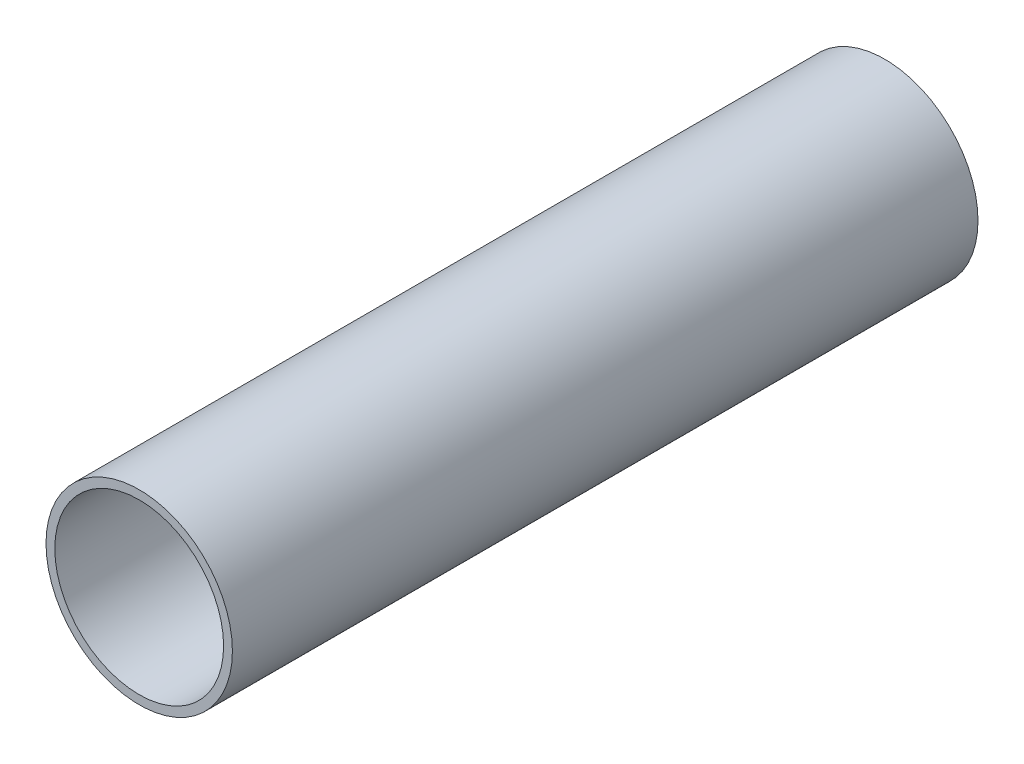
from build123d import *

# Parameters (mm, degrees)
SKETCH1_R           = 84.1375
SKETCH1_R_2         = 76.2
BOSS_EXTRUDE1_DEPTH = 673.1


with BuildPart() as part:
    # Sketch1 → Boss-Extrude1 (new body)
    with BuildSketch(Plane.XY):
        Circle(SKETCH1_R)
        Circle(SKETCH1_R_2, mode=Mode.SUBTRACT)
    extrude(amount=BOSS_EXTRUDE1_DEPTH)


solid = part.part
